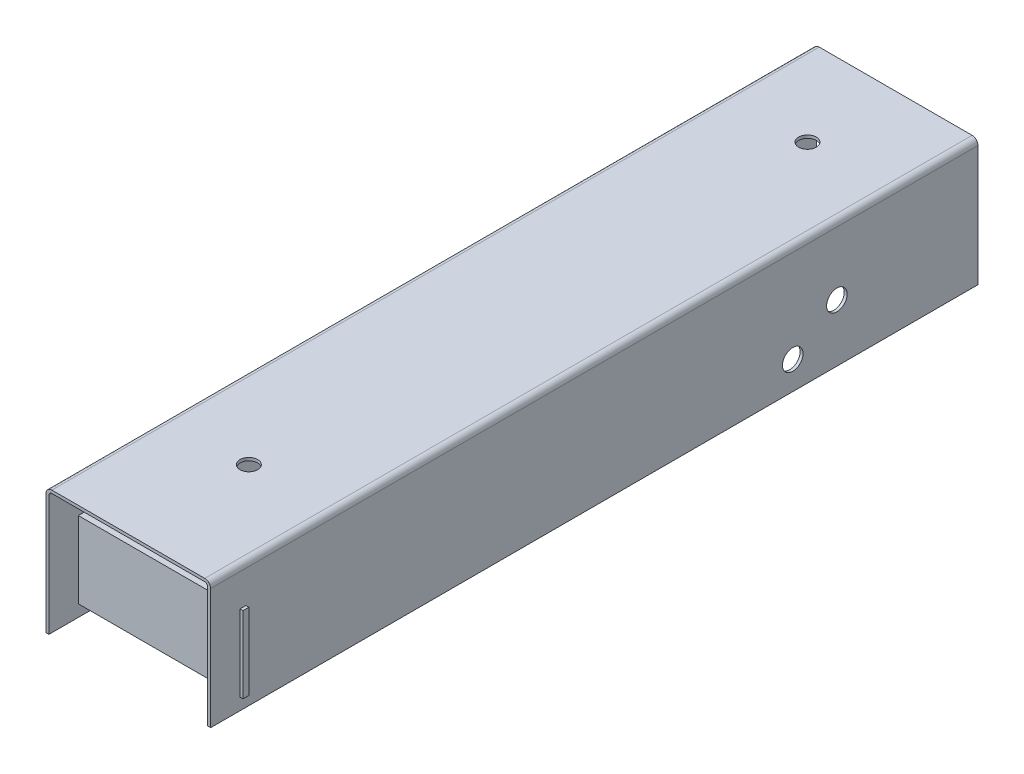
from build123d import *

# Parameters (mm, degrees)
BOSS_EXTRUDE1_DEPTH      = 261
FILLET1_R                = 2
FILLET2_R                = 1
BOSS_EXTRUDE2_DEPTH      = 56
BOSS_EXTRUDE2_DEPTH_BACK = 2
SKETCH2_W                = 2
SKETCH2_H                = 26
SKETCH3_R                = 3
CUT_EXTRUDE1_DEPTH       = 11
SKETCH4_W                = 30
SKETCH4_H                = 40
CUT_EXTRUDE2_DEPTH       = 10
SKETCH5_R                = 3.5
CUT_EXTRUDE3_DEPTH       = 69


with BuildPart() as part:
    # Sketch1 → Boss-Extrude1 (new body)
    with BuildSketch(Plane.XY):
        Polygon((27, -21.5), (27, -20.5), (27, 20.5), (-27, 20.5), (-27, -20.5), (-27, -21.5), (-28, -21.5), (-28, 21.5), (28, 21.5), (28, -21.5), align=None)
    extrude(amount=BOSS_EXTRUDE1_DEPTH)

    # Fillet1
    fillet1_edges = [part.edges().sort_by_distance(p)[0] for p in [
        (-28, 21.5, 130.5),
        (28, 21.5, 130.5),
    ]]
    fillet(fillet1_edges, radius=FILLET1_R)

    # Fillet2
    fillet2_edges = [part.edges().sort_by_distance(p)[0] for p in [
        (27, 20.5, 130.5),
        (-27, 20.5, 130.5),
    ]]
    fillet(fillet2_edges, radius=FILLET2_R)

    # Sketch2 → Boss-Extrude2 (add, two sides: drawn at the far end of the back side and taken through both)
    with BuildSketch(Plane(origin=(-27, 0, 0), x_dir=(0, 0, -1), z_dir=(1, 0, 0)).offset(-BOSS_EXTRUDE2_DEPTH_BACK)):
        with Locations((-250, -4.5)):
            Rectangle(SKETCH2_W, SKETCH2_H)
    extrude(amount=BOSS_EXTRUDE2_DEPTH + BOSS_EXTRUDE2_DEPTH_BACK)

    # Sketch3 → Cut-Extrude1 (cut)
    with BuildSketch(Plane(origin=(0, 21.5, 0), x_dir=(1, 0, 0), z_dir=(0, 1, 0))):
        with Locations(Location((0, -30, 0), (0, 0, 270))):
            Circle(SKETCH3_R)
        with Locations(Location((0, -220, 0), (0, 0, 270))):
            Circle(SKETCH3_R)
    extrude(amount=-CUT_EXTRUDE1_DEPTH, mode=Mode.SUBTRACT)

    # Sketch4 → Cut-Extrude2 (cut)
    with BuildSketch(Plane.ZY.offset(28)):
        with Locations((221, -3.5)):
            Rectangle(SKETCH4_W, SKETCH4_H)
    extrude(amount=-CUT_EXTRUDE2_DEPTH, mode=Mode.SUBTRACT)

    # Sketch5 → Cut-Extrude3 (cut)
    with BuildSketch(Plane.ZY.offset(28)):
        with Locations(Location((48, -2, 0), (0, 0, 270))):
            Circle(SKETCH5_R)
        with Locations(Location((63, -12, 0), (0, 0, 270))):
            Circle(SKETCH5_R)
    extrude(amount=-CUT_EXTRUDE3_DEPTH, mode=Mode.SUBTRACT)


solid = part.part
